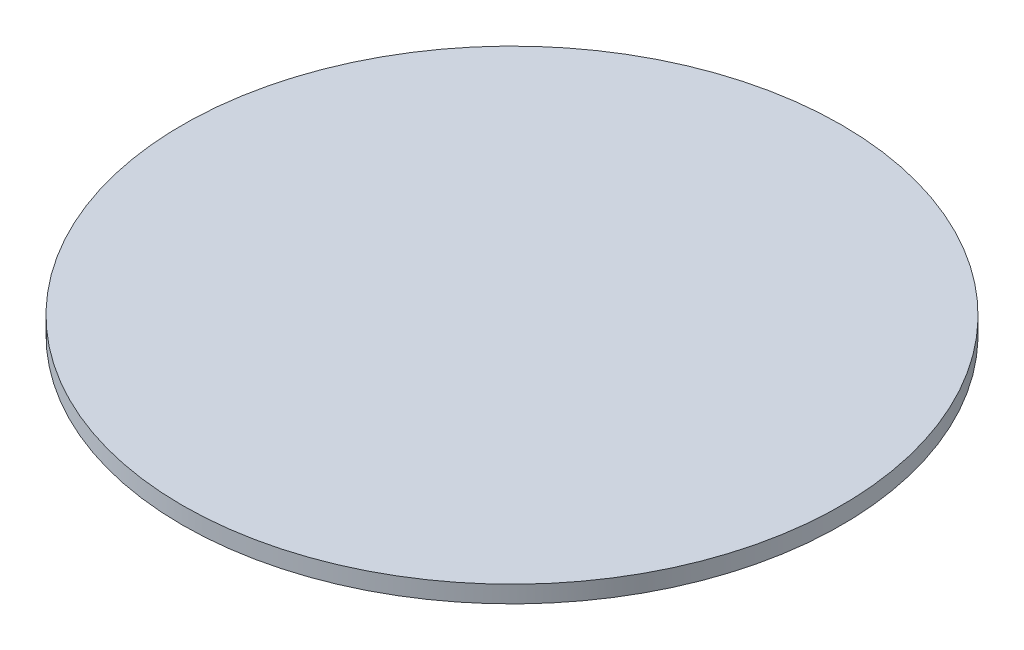
from build123d import *

# Parameters (mm, degrees)
SKETCH_1_R      = 29
EXTRUDE_1_DEPTH = 1.5


with BuildPart() as part:
    # Эскиз1 → Бобышка-Вытянуть1 (new body)
    with BuildSketch(Plane(origin=(0, 0, 0), x_dir=(1, 0, 0), z_dir=(0, 1, 0))):
        Circle(SKETCH_1_R)
    extrude(amount=EXTRUDE_1_DEPTH)


solid = part.part
